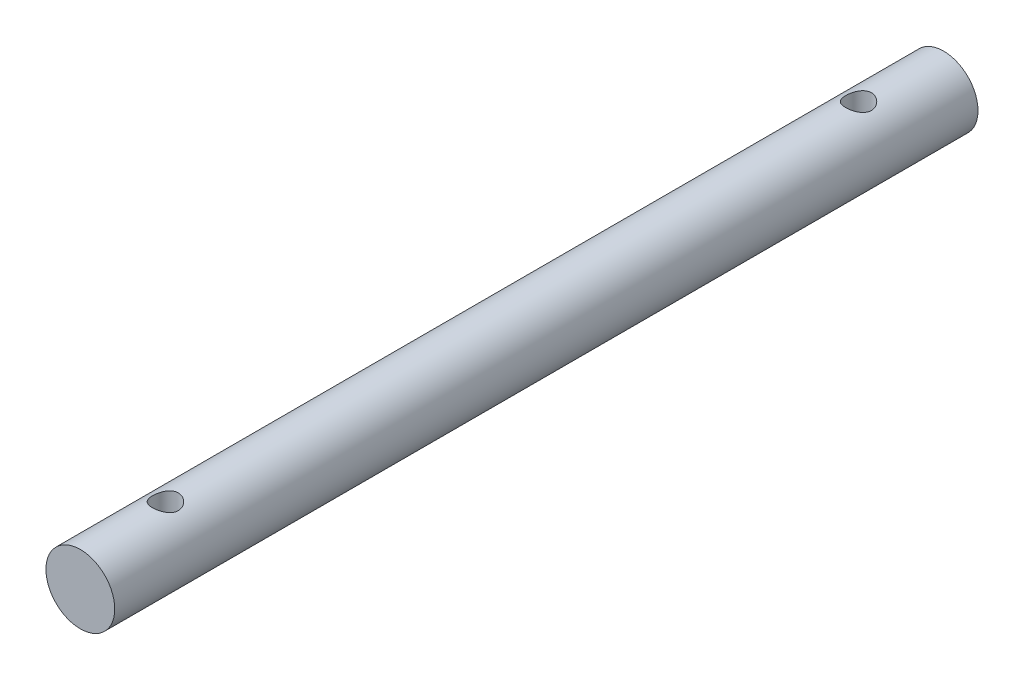
from build123d import *

# Parameters (mm, degrees)
SKETCH2_R               = 4
BOSS_EXTRUDE1_DEPTH     = 50.18
SKETCH3_R               = 1.5
CUT_EXTRUDE1_DEPTH      = 5
CUT_EXTRUDE1_DEPTH_BACK = 5


with BuildPart() as part:
    # Sketch2 → Boss-Extrude1 (new body, symmetric)
    with BuildSketch(Plane.XY):
        Circle(SKETCH2_R)
    extrude(amount=BOSS_EXTRUDE1_DEPTH, both=True)

    # Sketch3 → Cut-Extrude1 (cut, two sides)
    with BuildSketch(Plane(origin=(0, 0, 0), x_dir=(1, 0, 0), z_dir=(0, 1, 0))) as cut_extrude1_sk:
        with Locations((0, 40.29)):
            Circle(SKETCH3_R)
        with Locations((0, -40.29)):
            Circle(SKETCH3_R)
    extrude(amount=CUT_EXTRUDE1_DEPTH, mode=Mode.SUBTRACT)
    extrude(cut_extrude1_sk.sketch, amount=-CUT_EXTRUDE1_DEPTH_BACK, mode=Mode.SUBTRACT)


solid = part.part
